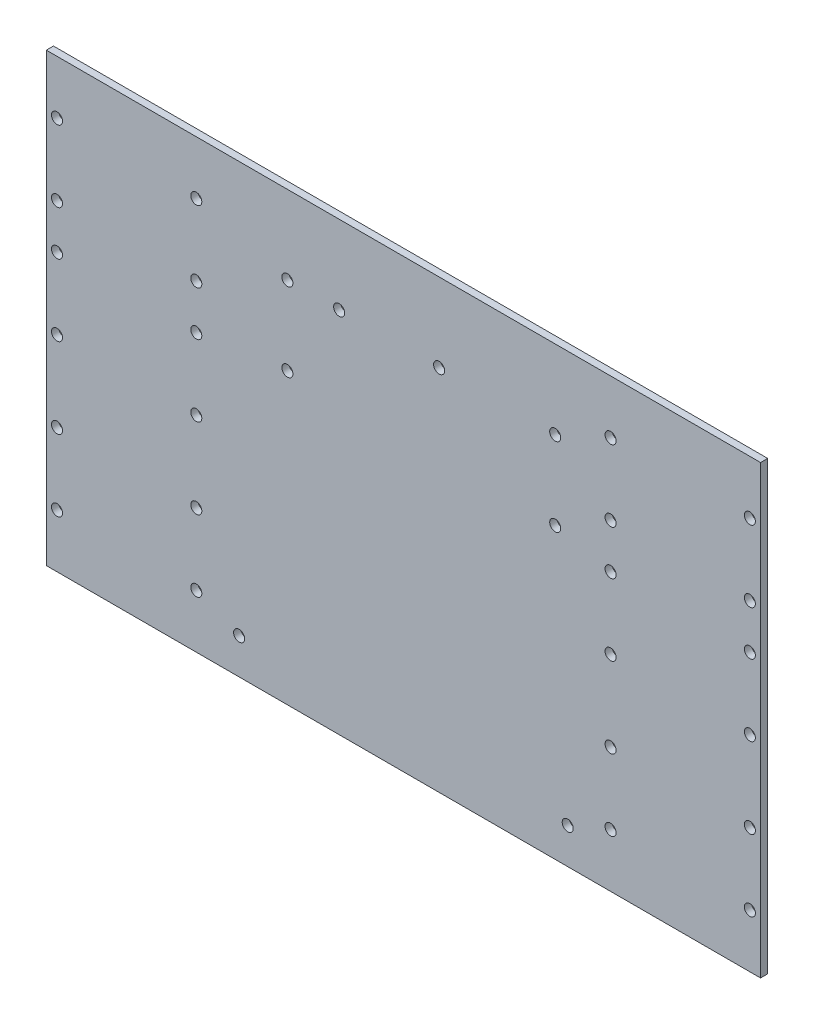
from build123d import *

# Parameters (mm, degrees)
SKETCH_1_W      = 200
SKETCH_1_H      = 125
SKETCH_1_R      = 1.55
EXTRUDE_1_DEPTH = 2


with BuildPart() as part:
    # 草图1 → 凸台-拉伸1 (new body)
    with BuildSketch(Plane.XY):
        Rectangle(SKETCH_1_W, SKETCH_1_H)
        with Locations((-97, -47.5)):
            Circle(SKETCH_1_R, mode=Mode.SUBTRACT)
        with Locations((-97, -27.5)):
            Circle(SKETCH_1_R, mode=Mode.SUBTRACT)
        with Locations((-97, 47.5)):
            Circle(SKETCH_1_R, mode=Mode.SUBTRACT)
        with Locations((-97, 27.5)):
            Circle(SKETCH_1_R, mode=Mode.SUBTRACT)
        with Locations((-97, -5)):
            Circle(SKETCH_1_R, mode=Mode.SUBTRACT)
        with Locations((-97, 15)):
            Circle(SKETCH_1_R, mode=Mode.SUBTRACT)
        with Locations((97, 47.5)):
            Circle(SKETCH_1_R, mode=Mode.SUBTRACT)
        with Locations((97, 27.5)):
            Circle(SKETCH_1_R, mode=Mode.SUBTRACT)
        with Locations((97, -27.5)):
            Circle(SKETCH_1_R, mode=Mode.SUBTRACT)
        with Locations((97, -47.5)):
            Circle(SKETCH_1_R, mode=Mode.SUBTRACT)
        with Locations((-58, 47.5)):
            Circle(SKETCH_1_R, mode=Mode.SUBTRACT)
        with Locations((-58, 27.5)):
            Circle(SKETCH_1_R, mode=Mode.SUBTRACT)
        with Locations((-58, -27.5)):
            Circle(SKETCH_1_R, mode=Mode.SUBTRACT)
        with Locations((-58, -47.5)):
            Circle(SKETCH_1_R, mode=Mode.SUBTRACT)
        with Locations((58, 47.5)):
            Circle(SKETCH_1_R, mode=Mode.SUBTRACT)
        with Locations((58, 27.5)):
            Circle(SKETCH_1_R, mode=Mode.SUBTRACT)
        with Locations((58, -47.5)):
            Circle(SKETCH_1_R, mode=Mode.SUBTRACT)
        with Locations((58, -27.5)):
            Circle(SKETCH_1_R, mode=Mode.SUBTRACT)
        with Locations((-58, -5)):
            Circle(SKETCH_1_R, mode=Mode.SUBTRACT)
        with Locations((-58, 15)):
            Circle(SKETCH_1_R, mode=Mode.SUBTRACT)
        with Locations((97, 15)):
            Circle(SKETCH_1_R, mode=Mode.SUBTRACT)
        with Locations((97, -5)):
            Circle(SKETCH_1_R, mode=Mode.SUBTRACT)
        with Locations((58, 15)):
            Circle(SKETCH_1_R, mode=Mode.SUBTRACT)
        with Locations((58, -5)):
            Circle(SKETCH_1_R, mode=Mode.SUBTRACT)
        with Locations((-32.5, 40.5)):
            Circle(SKETCH_1_R, mode=Mode.SUBTRACT)
        with Locations((-32.5, 18.5)):
            Circle(SKETCH_1_R, mode=Mode.SUBTRACT)
        with Locations((-18, 40.5)):
            Circle(SKETCH_1_R, mode=Mode.SUBTRACT)
        with Locations((10, 40.5)):
            Circle(SKETCH_1_R, mode=Mode.SUBTRACT)
        with Locations((42.5, 40.5)):
            Circle(SKETCH_1_R, mode=Mode.SUBTRACT)
        with Locations((42.5, 18.5)):
            Circle(SKETCH_1_R, mode=Mode.SUBTRACT)
        with Locations((-46, -52.5)):
            Circle(SKETCH_1_R, mode=Mode.SUBTRACT)
        with Locations((46, -52.5)):
            Circle(SKETCH_1_R, mode=Mode.SUBTRACT)
    extrude(amount=EXTRUDE_1_DEPTH)


solid = part.part
